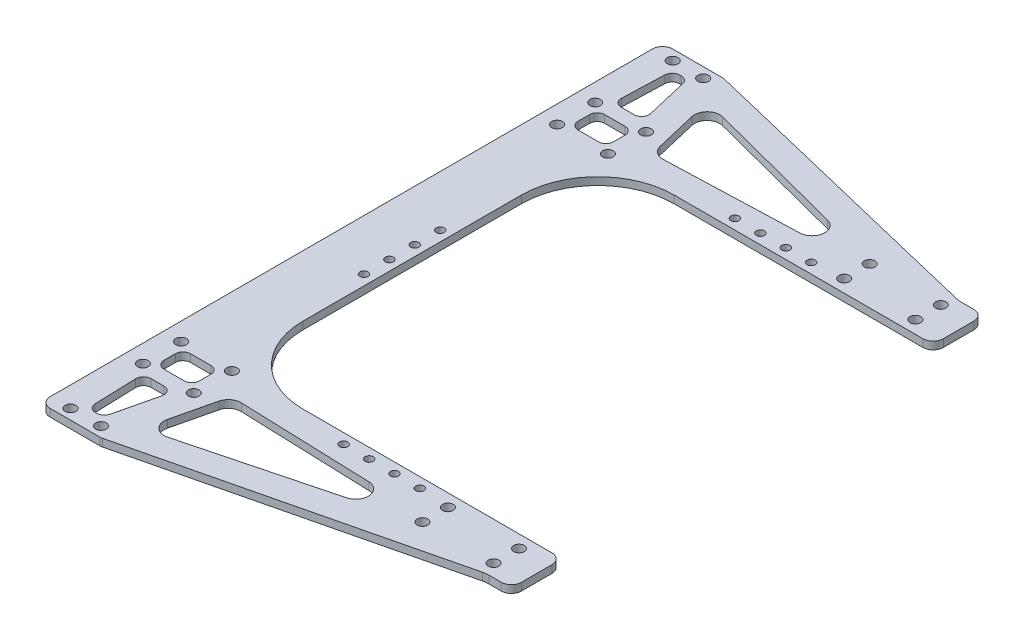
from build123d import *

# Parameters (mm, degrees)
SKETCH_1_R          = 2.1
EXTRUDE_1_DEPTH     = 3
FILLET_1_R          = 4
SKETCH_2_R          = 2.1
CUT_EXTRUDE_1_DEPTH = 4
EXTRUDE_2_DEPTH     = 3
FILLET_2_R          = 4
SKETCH_5_R          = 1.6
CUT_EXTRUDE_2_DEPTH = 4
FILLET_3_R          = 10
SKETCH_7_R          = 2.1
CUT_EXTRUDE_3_DEPTH = 4
CUT_EXTRUDE_4_DEPTH = 4


with BuildPart() as part:
    # 草图1 → 凸台-拉伸1 (new body)
    with BuildSketch(Plane(origin=(0, 0, 0), x_dir=(1, 0, 0), z_dir=(0, 1, 0))):
        with BuildLine():
            Line((-26, 93), (-96, 93))
            ThreePointArc((-96, 93), (-103.071067812, 95.928932188), (-106, 103))
            Line((-106, 103), (-106, 122.5))
            Line((-106, 122.5), (-130, 122.5))
            Line((-130, 122.5), (-130, -122.5))
            Line((-130, -122.5), (-106, -122.5))
            Line((-106, -122.5), (-106, -103))
            ThreePointArc((-106, -103), (-103.071067812, -95.928932188), (-96, -93))
            Line((-96, -93), (-26, -93))
            Line((-26, -93), (26, -93))
            Line((26, -93), (26, -73))
            Line((26, -73), (-76, -73))
            ThreePointArc((-76, -73), (-97.213203436, -64.213203436), (-106, -43))
            Line((-106, -43), (-106, 43))
            ThreePointArc((-106, 43), (-97.213203436, 64.213203436), (-76, 73))
            Line((-76, 73), (26, 73))
            Line((26, 73), (26, 93))
            Line((26, 93), (-26, 93))
        make_face()
        with Locations((-14, 88)):
            Circle(SKETCH_1_R, mode=Mode.SUBTRACT)
        with Locations((-14, 78)):
            Circle(SKETCH_1_R, mode=Mode.SUBTRACT)
        with Locations((14, 78)):
            Circle(SKETCH_1_R, mode=Mode.SUBTRACT)
        with Locations((14, 88)):
            Circle(SKETCH_1_R, mode=Mode.SUBTRACT)
        with Locations((14, -78)):
            Circle(SKETCH_1_R, mode=Mode.SUBTRACT)
        with Locations((14, -88)):
            Circle(SKETCH_1_R, mode=Mode.SUBTRACT)
        with Locations((-14, -78)):
            Circle(SKETCH_1_R, mode=Mode.SUBTRACT)
        with Locations((-14, -88)):
            Circle(SKETCH_1_R, mode=Mode.SUBTRACT)
    extrude(amount=EXTRUDE_1_DEPTH)

    # 圆角1
    fillet_1_edges = [part.edges().sort_by_distance(p)[0] for p in [
        (26, 1.5, -73),
        (26, 1.5, 73),
        (-130, 1.5, 122.5),
        (-130, 1.5, -122.5),
    ]]
    fillet(fillet_1_edges, radius=FILLET_1_R)

    # 草图2 → 切除-拉伸1 (cut, through all)
    with BuildSketch(Plane(origin=(0, 3, 0), x_dir=(1, 0, 0), z_dir=(0, 1, 0))):
        with Locations((-122, 118.5)):
            Circle(SKETCH_2_R)
        with Locations((-110, 118.5)):
            Circle(SKETCH_2_R)
        with Locations((-122, -118.5)):
            Circle(SKETCH_2_R)
        with Locations((-110, -118.5)):
            Circle(SKETCH_2_R)
    extrude(amount=-CUT_EXTRUDE_1_DEPTH, mode=Mode.SUBTRACT)

    # 草图4 → 凸台-拉伸2 (add)
    with BuildSketch(Plane(origin=(0, 3, 0), x_dir=(1, 0, 0), z_dir=(0, 1, 0))):
        Polygon((-106, 122.5), (16, 93), (-106, 93), align=None)
        Polygon((16, -93), (-106, -93), (-106, -122.5), align=None)
    extrude(amount=-EXTRUDE_2_DEPTH)

    # 圆角2
    fillet_2_edges = [part.edges().sort_by_distance(p)[0] for p in [
        (26, 1.5, 93),
        (-106, 1.5, 122.5),
        (-106, 1.5, -122.5),
        (26, 1.5, -93),
    ]]
    fillet(fillet_2_edges, radius=FILLET_2_R)

    # 草图5 → 切除-拉伸2 (cut, through all)
    with BuildSketch(Plane.XZ):
        with Locations((-110, -15)):
            Circle(SKETCH_5_R)
        with Locations((-110, -5)):
            Circle(SKETCH_5_R)
        with Locations((-110, 5)):
            Circle(SKETCH_5_R)
        with Locations((-110, 15)):
            Circle(SKETCH_5_R)
        with Locations((-26, -77)):
            Circle(SKETCH_5_R)
        with Locations((-36, -77)):
            Circle(SKETCH_5_R)
        with Locations((-46, -77)):
            Circle(SKETCH_5_R)
        with Locations((-56, -77)):
            Circle(SKETCH_5_R)
        with Locations((-56, 77)):
            Circle(SKETCH_5_R)
        with Locations((-46, 77)):
            Circle(SKETCH_5_R)
        with Locations((-36, 77)):
            Circle(SKETCH_5_R)
        with Locations((-26, 77)):
            Circle(SKETCH_5_R)
    extrude(amount=-CUT_EXTRUDE_2_DEPTH, mode=Mode.SUBTRACT)

    # 圆角3
    fillet_3_edges = [part.edges().sort_by_distance(p)[0] for p in [
        (16, 1.5, -93),
        (16, 1.5, 93),
    ]]
    fillet(fillet_3_edges, radius=FILLET_3_R)

    # 草图7 → 切除-拉伸3 (cut, through all)
    with BuildSketch(Plane(origin=(0, 3, 0), x_dir=(1, 0, 0), z_dir=(0, 1, 0))):
        with Locations((-123, -74)):
            Circle(SKETCH_7_R)
        with Locations((-103, -74)):
            Circle(SKETCH_7_R)
        with Locations((-103, -89)):
            Circle(SKETCH_7_R)
        with Locations((-123, -89)):
            Circle(SKETCH_7_R)
        with Locations((-123, 89)):
            Circle(SKETCH_7_R)
        with Locations((-103, 89)):
            Circle(SKETCH_7_R)
        with Locations((-103, 74)):
            Circle(SKETCH_7_R)
        with Locations((-123, 74)):
            Circle(SKETCH_7_R)
    extrude(amount=-CUT_EXTRUDE_3_DEPTH, mode=Mode.SUBTRACT)

    # 草图8 → 切除-拉伸4 (cut, through all)
    with BuildSketch(Plane(origin=(0, 3, 0), x_dir=(1, 0, 0), z_dir=(0, 1, 0))):
        with BuildLine():
            Line((-99.173057144, 103.191305263), (-95.290856101, 86.83060087))
            ThreePointArc((-95.290856101, 86.83060087), (-93.457663057, 84.008976045), (-90.251444241, 82.988033197))
            Line((-90.251444241, 82.988033197), (-38.266720564, 84.80337975))
            ThreePointArc((-38.266720564, 84.80337975), (-33.471381612, 89.251949162), (-37.181429777, 94.639025187))
            Line((-37.181429777, 94.639025187), (-93.048354496, 109.184383027))
            ThreePointArc((-93.048354496, 109.184383027), (-97.805066963, 107.919418235), (-99.173057144, 103.191305263))
        make_face()
        with BuildLine():
            Line((-109, 86.75), (-117, 86.75))
            ThreePointArc((-117, 86.75), (-119.121320344, 85.871320344), (-120, 83.75))
            Line((-120, 83.75), (-120, 79.25))
            ThreePointArc((-120, 79.25), (-119.121320344, 77.128679656), (-117, 76.25))
            Line((-117, 76.25), (-109, 76.25))
            ThreePointArc((-109, 76.25), (-106.878679656, 77.128679656), (-106, 79.25))
            Line((-106, 79.25), (-106, 83.75))
            ThreePointArc((-106, 83.75), (-106.878679656, 85.871320344), (-109, 86.75))
        make_face()
        with BuildLine():
            Line((-109, -76.25), (-117, -76.25))
            ThreePointArc((-117, -76.25), (-119.121320344, -77.128679656), (-120, -79.25))
            Line((-120, -79.25), (-120, -83.75))
            ThreePointArc((-120, -83.75), (-119.121320344, -85.871320344), (-117, -86.75))
            Line((-117, -86.75), (-109, -86.75))
            ThreePointArc((-109, -86.75), (-106.878679656, -85.871320344), (-106, -83.75))
            Line((-106, -83.75), (-106, -79.25))
            ThreePointArc((-106, -79.25), (-106.878679656, -77.128679656), (-109, -76.25))
        make_face()
        with BuildLine():
            Line((-115.138114684, 115), (-115.716605496, 115))
            ThreePointArc((-115.716605496, 115), (-117.80168228, 114.156954985), (-118.714883338, 112.101636537))
            Line((-118.714883338, 112.101636537), (-119.274205372, 95.601636537))
            ThreePointArc((-119.274205372, 95.601636537), (-118.432882515, 93.414923216), (-116.27592753, 92.5))
            Line((-116.27592753, 92.5), (-111.222860446, 92.5))
            ThreePointArc((-111.222860446, 92.5), (-108.869363513, 93.639609669), (-108.30391182, 96.192631877))
            Line((-108.30391182, 96.192631877), (-112.219166057, 112.692631877))
            ThreePointArc((-112.219166057, 112.692631877), (-113.277724353, 114.353496934), (-115.138114684, 115))
        make_face()
        with BuildLine():
            Line((-37.181429777, -94.639025187), (-93.048354496, -109.184383027))
            ThreePointArc((-93.048354496, -109.184383027), (-97.805066963, -107.919418235), (-99.173057144, -103.191305263))
            Line((-99.173057144, -103.191305263), (-95.290856101, -86.83060087))
            ThreePointArc((-95.290856101, -86.83060087), (-93.457663057, -84.008976045), (-90.251444241, -82.988033197))
            Line((-90.251444241, -82.988033197), (-38.266720564, -84.80337975))
            ThreePointArc((-38.266720564, -84.80337975), (-33.471381612, -89.251949162), (-37.181429777, -94.639025187))
        make_face()
        with BuildLine():
            Line((-112.219166057, -112.692631877), (-108.30391182, -96.192631877))
            ThreePointArc((-108.30391182, -96.192631877), (-108.869363513, -93.639609669), (-111.222860446, -92.5))
            Line((-111.222860446, -92.5), (-116.27592753, -92.5))
            ThreePointArc((-116.27592753, -92.5), (-118.432882515, -93.414923216), (-119.274205372, -95.601636537))
            Line((-119.274205372, -95.601636537), (-118.714883338, -112.101636537))
            ThreePointArc((-118.714883338, -112.101636537), (-117.80168228, -114.156954985), (-115.716605496, -115))
            Line((-115.716605496, -115), (-115.138114684, -115))
            ThreePointArc((-115.138114684, -115), (-113.277724353, -114.353496934), (-112.219166057, -112.692631877))
        make_face()
    extrude(amount=-CUT_EXTRUDE_4_DEPTH, mode=Mode.SUBTRACT)


solid = part.part
